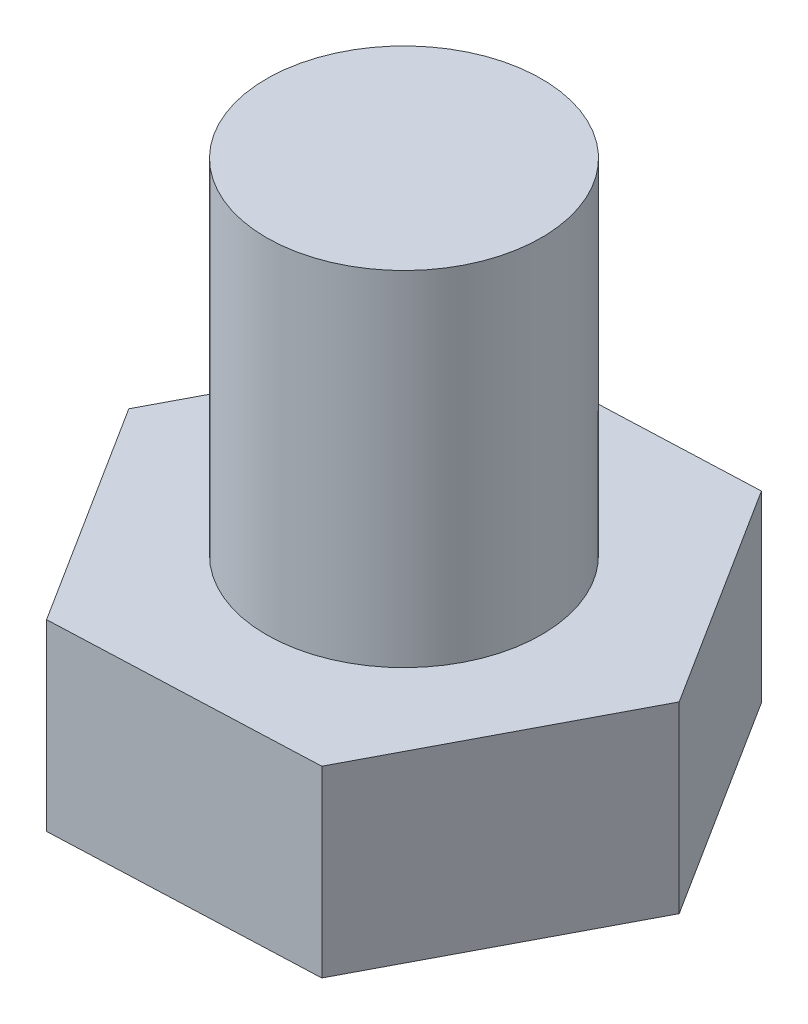
from build123d import *

# Parameters (mm, degrees)
SALIENTE_EXTRUIR1_DEPTH = 8
CROQUIS2_R              = 6
SALIENTE_EXTRUIR2_DEPTH = 15


with BuildPart() as part:
    # Croquis1 → Saliente-Extruir1 (new body)
    with BuildSketch(Plane(origin=(0, 0, 0), x_dir=(1, 0, 0), z_dir=(0, 1, 0))):
        Polygon((6.172295023, -9.758898887), (11.53760186, 0.465914846), (5.365306838, 10.224813733), (-6.172295023, 9.758898887), (-11.53760186, -0.465914846), (-5.365306838, -10.224813733), align=None)
    extrude(amount=SALIENTE_EXTRUIR1_DEPTH)

    # Croquis2 → Saliente-Extruir2 (add)
    with BuildSketch(Plane(origin=(0, 8, 0), x_dir=(1, 0, 0), z_dir=(0, 1, 0))):
        Circle(CROQUIS2_R)
    extrude(amount=SALIENTE_EXTRUIR2_DEPTH)


solid = part.part
